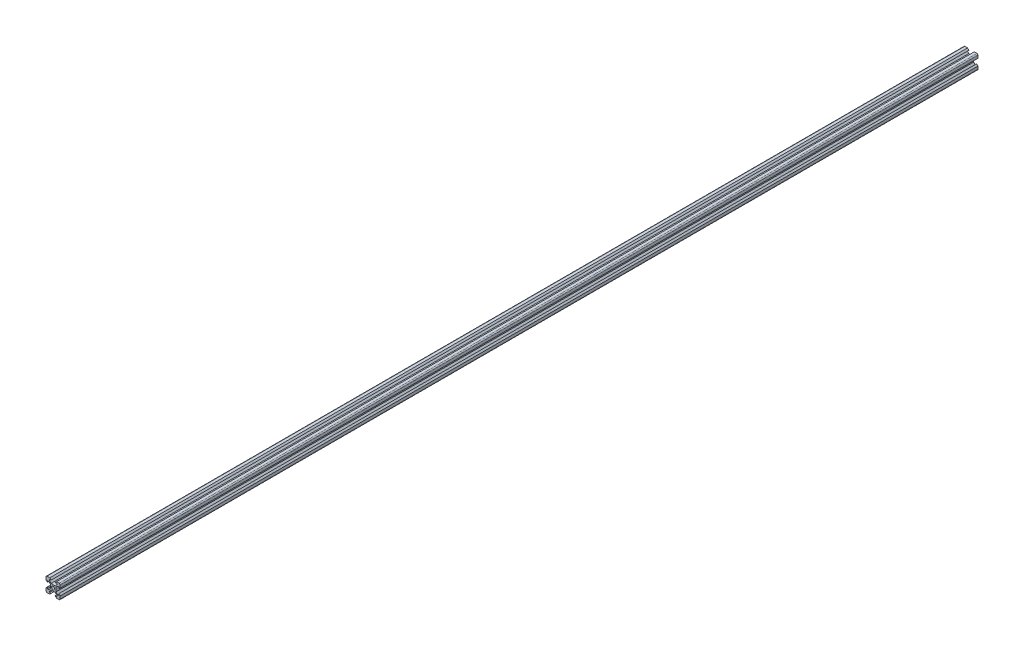
from build123d import *

# Parameters (mm, degrees)
SKETCH1_R           = 2.125
BOSS_EXTRUDE1_DEPTH = 1292.4


with BuildPart() as part:
    # Sketch1 → Boss-Extrude1 (new body)
    with BuildSketch(Plane.XY):
        with BuildLine():
            Line((8.1, 5.225), (8.1, 2.85))
            Line((8.1, 2.85), (10, 4.75))
            Line((10, 4.75), (10, 8.5))
            ThreePointArc((10, 8.5), (9.560660172, 9.560660172), (8.5, 10))
            Line((8.5, 10), (4.75, 10))
            Line((4.75, 10), (2.85, 8.1))
            Line((2.85, 8.1), (5.225, 8.1))
            Line((5.225, 8.1), (5.225, 6.325))
            Line((5.225, 6.325), (2.9, 4))
            Line((2.9, 4), (-2.9, 4))
            Line((-2.9, 4), (-5.225, 6.325))
            Line((-5.225, 6.325), (-5.225, 8.1))
            Line((-5.225, 8.1), (-2.85, 8.1))
            Line((-2.85, 8.1), (-4.75, 10))
            Line((-4.75, 10), (-8.5, 10))
            ThreePointArc((-8.5, 10), (-9.560660172, 9.560660172), (-10, 8.5))
            Line((-10, 8.5), (-10, 4.75))
            Line((-10, 4.75), (-8.1, 2.85))
            Line((-8.1, 2.85), (-8.1, 5.225))
            Line((-8.1, 5.225), (-6.325, 5.225))
            Line((-6.325, 5.225), (-4, 2.9))
            Line((-4, 2.9), (-4, -2.9))
            Line((-4, -2.9), (-6.325, -5.225))
            Line((-6.325, -5.225), (-8.1, -5.225))
            Line((-8.1, -5.225), (-8.1, -2.85))
            Line((-8.1, -2.85), (-10, -4.75))
            Line((-10, -4.75), (-10, -8.5))
            ThreePointArc((-10, -8.5), (-9.560660172, -9.560660172), (-8.5, -10))
            Line((-8.5, -10), (-4.75, -10))
            Line((-4.75, -10), (-2.85, -8.1))
            Line((-2.85, -8.1), (-5.225, -8.1))
            Line((-5.225, -8.1), (-5.225, -6.325))
            Line((-5.225, -6.325), (-2.9, -4))
            Line((-2.9, -4), (2.9, -4))
            Line((2.9, -4), (5.225, -6.325))
            Line((5.225, -6.325), (5.225, -8.1))
            Line((5.225, -8.1), (2.85, -8.1))
            Line((2.85, -8.1), (4.75, -10))
            Line((4.75, -10), (8.5, -10))
            ThreePointArc((8.5, -10), (9.560660172, -9.560660172), (10, -8.5))
            Line((10, -8.5), (10, -4.75))
            Line((10, -4.75), (8.1, -2.85))
            Line((8.1, -2.85), (8.1, -5.225))
            Line((8.1, -5.225), (6.325, -5.225))
            Line((6.325, -5.225), (4, -2.9))
            Line((4, -2.9), (4, 2.9))
            Line((4, 2.9), (6.325, 5.225))
            Line((6.325, 5.225), (8.1, 5.225))
        make_face()
        Circle(SKETCH1_R, mode=Mode.SUBTRACT)
    extrude(amount=BOSS_EXTRUDE1_DEPTH)


solid = part.part
